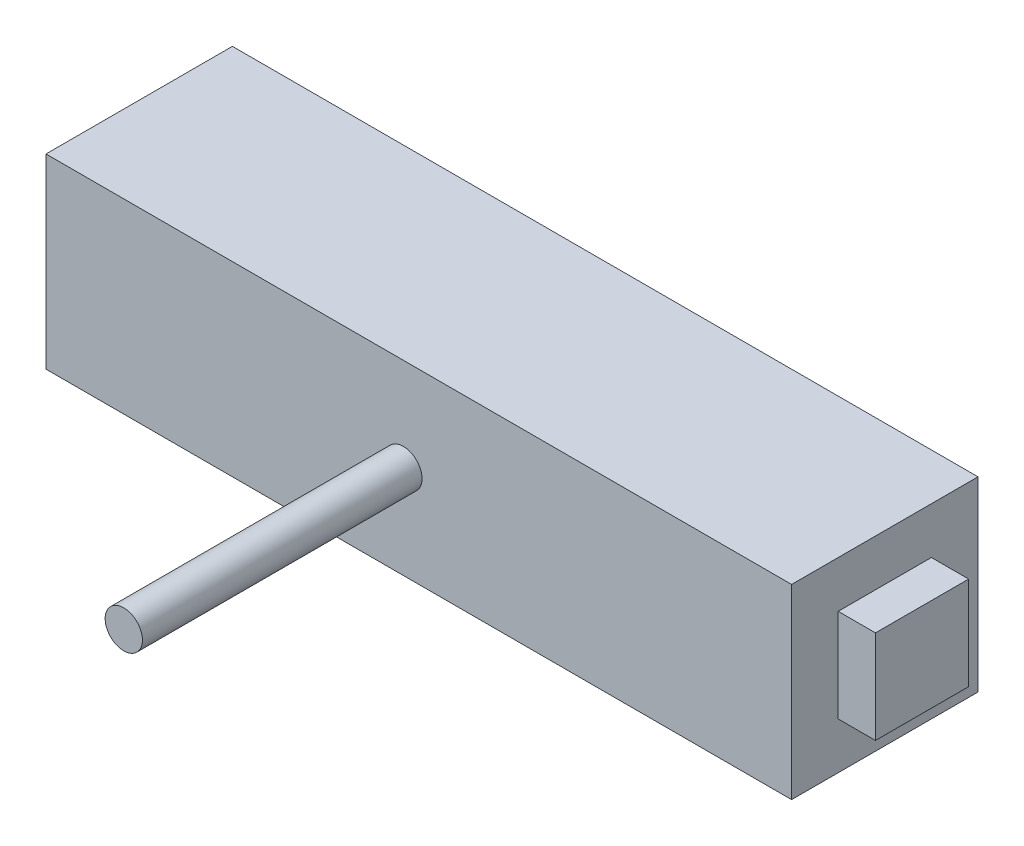
from build123d import *

# Parameters (mm, degrees)
SKETCH1_W           = 101.6
SKETCH1_H           = 25.4
BOSS_EXTRUDE1_DEPTH = 25.4
SKETCH2_W           = 12.7
SKETCH2_H           = 12.7
BOSS_EXTRUDE2_DEPTH = 5.08
SKETCH6_R           = 2.54
BOSS_EXTRUDE4_DEPTH = 38.1


with BuildPart() as part:
    # Sketch1 → Boss-Extrude1 (new body)
    with BuildSketch(Plane(origin=(0, 0, 0), x_dir=(1, 0, 0), z_dir=(0, 1, 0))):
        Rectangle(SKETCH1_W, SKETCH1_H)
    extrude(amount=BOSS_EXTRUDE1_DEPTH)

    # Sketch2 → Boss-Extrude2 (add)
    with BuildSketch(Plane(origin=(50.8, 0, 0), x_dir=(0, 0, -1), z_dir=(1, 0, 0))):
        with Locations((0, 12.7)):
            Rectangle(SKETCH2_W, SKETCH2_H)
    extrude(amount=BOSS_EXTRUDE2_DEPTH)

    # Sketch6 → Boss-Extrude4 (add)
    with BuildSketch(Plane.XY.offset(12.7)):
        with Locations((-2.101074924, 12.7)):
            Circle(SKETCH6_R)
    extrude(amount=BOSS_EXTRUDE4_DEPTH)


solid = part.part
